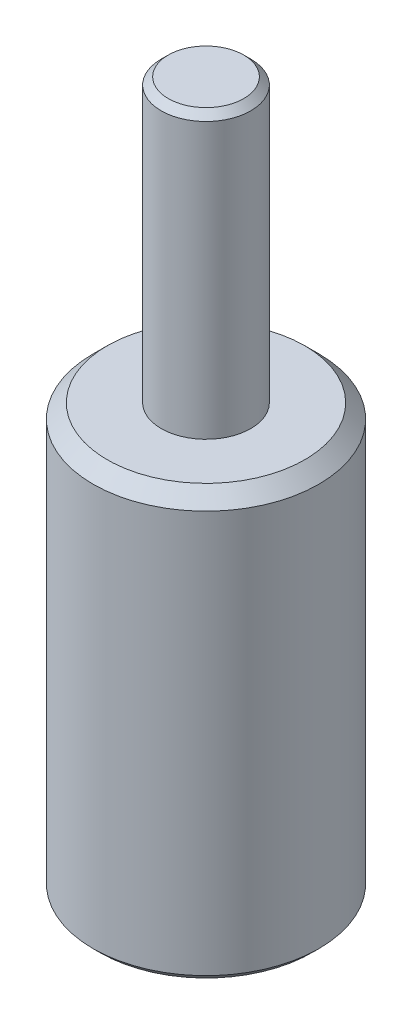
from build123d import *

# Parameters (mm, degrees)
CHANFREIN1_SIZE                     = 1
CHANFREIN2_SIZE                     = 0.5
DIAM_TRE_DU_PER_AGE_6_3_6_3_1_D     = 6.35
DIAM_TRE_DU_PER_AGE_6_3_6_3_1_DEPTH = 20
DIAM_TRE_DU_PER_AGE_6_3_6_3_1_TIP   = 1.907732465


with BuildPart() as part:
    # Esquisse1 → Révolution1 (revolve)
    with BuildSketch(Plane.XY):
        Polygon((0, 0), (8, 0), (8, 30), (3.175, 30), (3.175, 50), (0, 50), align=None)
    revolve(axis=Axis((0, 50, 0), (0, -1, 0)))

    # Chanfrein1
    chanfrein1_edges = [part.edges().sort_by_distance(p)[0] for p in [
        (-8, 30, 0),
    ]]
    chamfer(chanfrein1_edges, length=CHANFREIN1_SIZE)

    # Chanfrein2
    chanfrein2_edges = [part.edges().sort_by_distance(p)[0] for p in [
        (-8, 0, 0),
        (-3.175, 50, 0),
    ]]
    chamfer(chanfrein2_edges, length=CHANFREIN2_SIZE)

    # Diamètre du perçage Ø6.3 (6.3)1
    with Locations(Plane(origin=(0, 0, 0), x_dir=(-1, 0, 0), z_dir=(0, -1, 0))):
        with Locations((0, 0)):
            Hole(DIAM_TRE_DU_PER_AGE_6_3_6_3_1_D / 2, depth=DIAM_TRE_DU_PER_AGE_6_3_6_3_1_DEPTH)
            with Locations((0, 0, -(DIAM_TRE_DU_PER_AGE_6_3_6_3_1_DEPTH + DIAM_TRE_DU_PER_AGE_6_3_6_3_1_TIP / 2))):  # 118° drill point
                Cone(0, DIAM_TRE_DU_PER_AGE_6_3_6_3_1_D / 2, DIAM_TRE_DU_PER_AGE_6_3_6_3_1_TIP, mode=Mode.SUBTRACT)


solid = part.part
